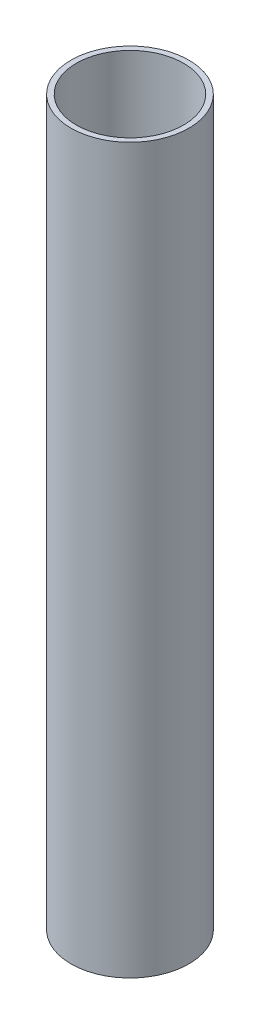
from build123d import *

# Parameters (mm, degrees)
SKETCH_1_R      = 11
SKETCH_1_R_2    = 10
EXTRUDE_1_DEPTH = 135


with BuildPart() as part:
    # 草图1 → 凸台-拉伸1 (new body)
    with BuildSketch(Plane(origin=(0, 0, 0), x_dir=(1, 0, 0), z_dir=(0, 1, 0))):
        Circle(SKETCH_1_R)
        Circle(SKETCH_1_R_2, mode=Mode.SUBTRACT)
    extrude(amount=EXTRUDE_1_DEPTH)


solid = part.part
